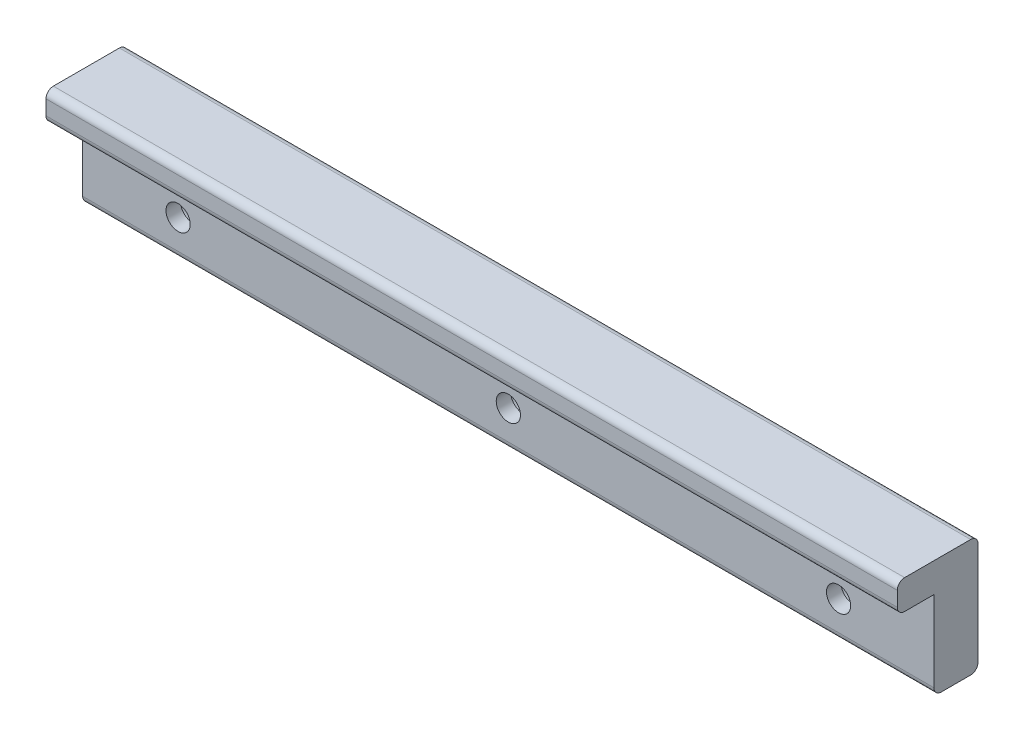
from build123d import *

# Parameters (mm, degrees)
BOSS_EXTRUDE1_DEPTH = 116
CUT_EXTRUDE1_REACH  = 13
SKETCH3_R           = 1.65
SKETCH4_R           = 3
CUT_EXTRUDE2_DEPTH  = 4
FILLET1_R           = 1


with BuildPart() as part:
    # Sketch2 → Boss-Extrude1 (new body)
    with BuildSketch(Plane(origin=(0, 0, 0), x_dir=(0, 0, -1), z_dir=(1, 0, 0))):
        Polygon((0, 0), (0, 12), (-5, 12), (-5, 16), (6, 16), (6, 0), align=None)
    extrude(amount=BOSS_EXTRUDE1_DEPTH)

    # Sketch3 → Cut-Extrude1 (cut, up to next)
    with BuildSketch(Plane(origin=(0, 0, -6), x_dir=(-1, 0, 0), z_dir=(0, 0, -1)), mode=Mode.PRIVATE) as cut_extrude1_sk1:
        with Locations((-103, 5)):
            Circle(SKETCH3_R)
    cut_extrude1_tool1 = extrude(cut_extrude1_sk1.sketch, amount=-CUT_EXTRUDE1_REACH, mode=Mode.PRIVATE) & part.part
    add(cut_extrude1_tool1.solids().sort_by_distance((103, 5, -6))[0], mode=Mode.SUBTRACT)
    # Sketch3 → Cut-Extrude1 (cut, up to next)
    with BuildSketch(Plane(origin=(0, 0, -6), x_dir=(-1, 0, 0), z_dir=(0, 0, -1)), mode=Mode.PRIVATE) as cut_extrude1_sk2:
        with Locations((-13, 5)):
            Circle(SKETCH3_R)
    cut_extrude1_tool2 = extrude(cut_extrude1_sk2.sketch, amount=-CUT_EXTRUDE1_REACH, mode=Mode.PRIVATE) & part.part
    add(cut_extrude1_tool2.solids().sort_by_distance((13, 5, -6))[0], mode=Mode.SUBTRACT)
    # Sketch3 → Cut-Extrude1 (cut, up to next)
    with BuildSketch(Plane(origin=(0, 0, -6), x_dir=(-1, 0, 0), z_dir=(0, 0, -1)), mode=Mode.PRIVATE) as cut_extrude1_sk3:
        with Locations((-58, 5)):
            Circle(SKETCH3_R)
    cut_extrude1_tool3 = extrude(cut_extrude1_sk3.sketch, amount=-CUT_EXTRUDE1_REACH, mode=Mode.PRIVATE) & part.part
    add(cut_extrude1_tool3.solids().sort_by_distance((58, 5, -6))[0], mode=Mode.SUBTRACT)

    # Sketch4 → Cut-Extrude2 (cut)
    with BuildSketch(Plane(origin=(0, 0, -6), x_dir=(-1, 0, 0), z_dir=(0, 0, -1))):
        with Locations((-103, 5)):
            Circle(SKETCH4_R)
        with Locations((-58, 5)):
            Circle(SKETCH4_R)
        with Locations((-13, 5)):
            Circle(SKETCH4_R)
    extrude(amount=-CUT_EXTRUDE2_DEPTH, mode=Mode.SUBTRACT)

    # Fillet1
    fillet1_edges = [part.edges().sort_by_distance(p)[0] for p in [
        (58, 0, 0),
        (58, 12, 5),
        (58, 16, 5),
        (58, 16, -6),
        (58, 0, -6),
    ]]
    fillet(fillet1_edges, radius=FILLET1_R)


solid = part.part
